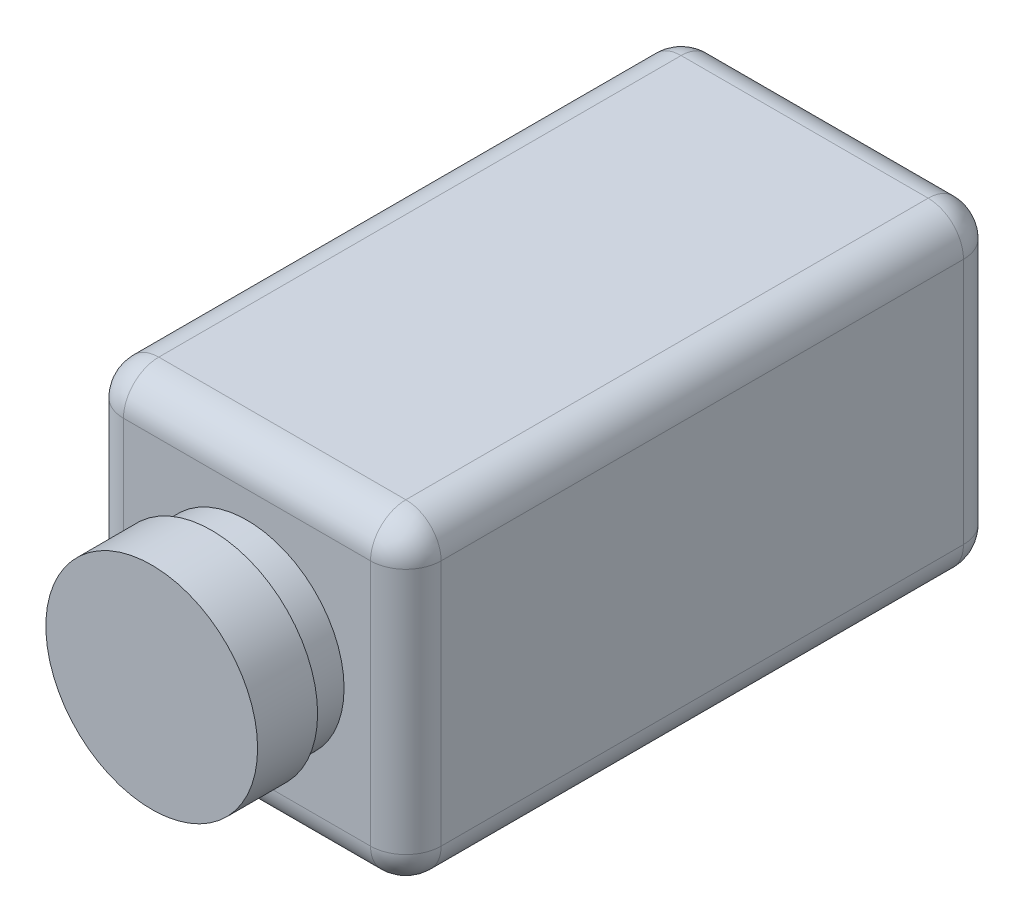
from build123d import *

# Parameters (mm, degrees)
SKETCH_1_W      = 90
SKETCH_1_H      = 90
EXTRUDE_1_DEPTH = 168
FILLET_1_R      = 10
SKETCH_2_R      = 27.5
EXTRUDE_2_DEPTH = 10
SKETCH_3_R      = 30
EXTRUDE_3_DEPTH = 17


with BuildPart() as part:
    # 스케치1 → 보스-돌출1 (new body)
    with BuildSketch(Plane.XY):
        with Locations((45, -45)):
            Rectangle(SKETCH_1_W, SKETCH_1_H)
    extrude(amount=EXTRUDE_1_DEPTH)

    # 필렛1
    fillet_1_edges = [part.edges().sort_by_distance(p)[0] for p in [
        (90, -45, 168),
        (45, 0, 168),
        (0, -45, 168),
        (45, 0, 0),
        (90, -45, 0),
        (45, -90, 0),
        (0, -45, 0),
        (45, -90, 168),
        (0, 0, 84),
        (90, 0, 84),
        (90, -90, 84),
        (0, -90, 84),
    ]]
    fillet(fillet_1_edges, radius=FILLET_1_R)

    # 스케치2 → 보스-돌출2 (add)
    with BuildSketch(Plane.XY.offset(168)):
        with Locations((45, -45)):
            Circle(SKETCH_2_R)
    extrude(amount=EXTRUDE_2_DEPTH)

    # 스케치3 → 보스-돌출3 (add)
    with BuildSketch(Plane.XY.offset(178)):
        with Locations((45, -45)):
            Circle(SKETCH_3_R)
    extrude(amount=EXTRUDE_3_DEPTH)


solid = part.part
